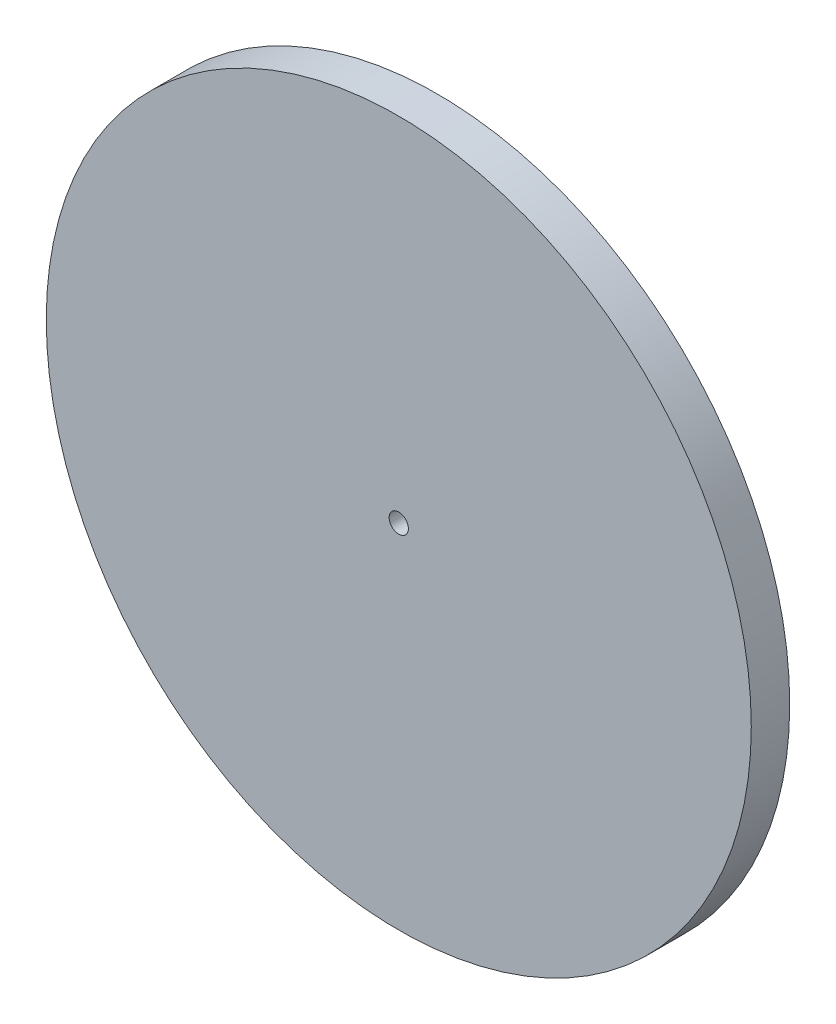
from build123d import *

# Parameters (mm, degrees)
SKETCH1_R           = 27.5
SKETCH1_R_2         = 0.75
BOSS_EXTRUDE1_DEPTH = 3


with BuildPart() as part:
    # Sketch1 → Boss-Extrude1 (new body)
    with BuildSketch(Plane.XY):
        Circle(SKETCH1_R)
        Circle(SKETCH1_R_2, mode=Mode.SUBTRACT)
    extrude(amount=BOSS_EXTRUDE1_DEPTH)


solid = part.part
